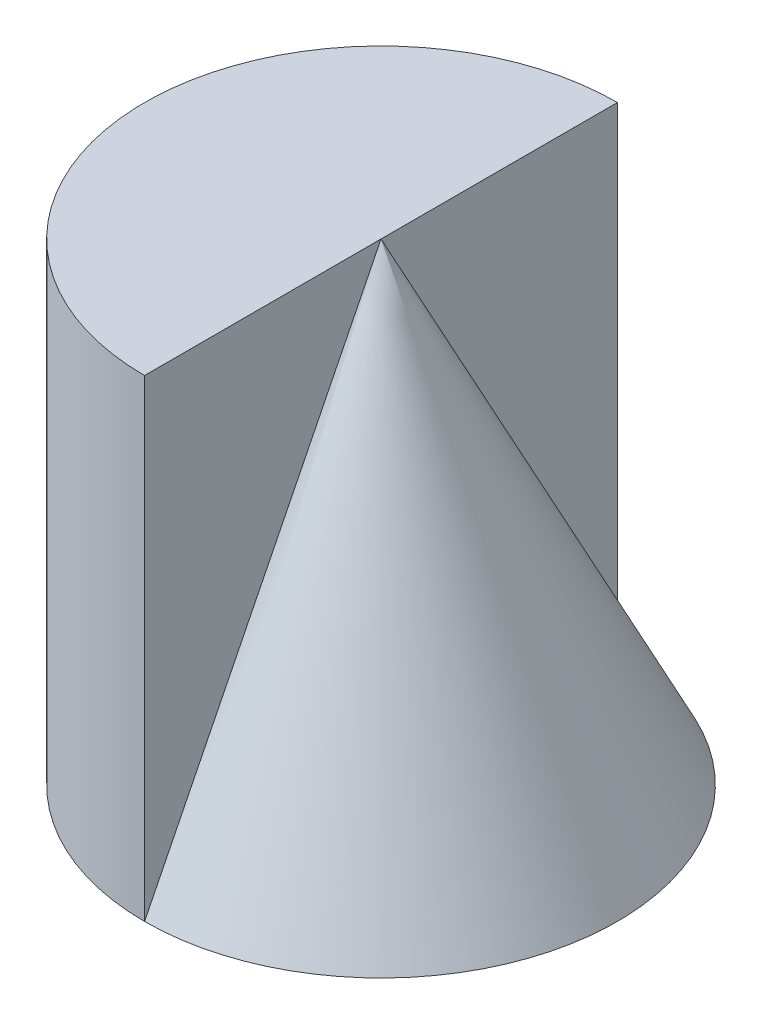
from build123d import *

# Parameters (mm, degrees)
SKETCH1_W           = 2
SKETCH1_H           = 4
BOSS_EXTRUDE1_DEPTH = 4
REVOLVE1_ANGLE      = 180
CUT_EXTRUDE1_DEPTH  = 4


with BuildPart() as part:
    # Sketch1 → Boss-Extrude1 (new body)
    with BuildSketch(Plane.XY):
        with Locations((1, 2)):
            Rectangle(SKETCH1_W, SKETCH1_H)
    extrude(amount=BOSS_EXTRUDE1_DEPTH)

    # Sketch2 → Revolve1 (revolve)
    with BuildSketch(Plane(origin=(2, 0, 0), x_dir=(0, 0, -1), z_dir=(1, 0, 0))):
        Polygon((-2, 0), (-2, 4), (0, 0), align=None)
    revolve(axis=Axis((2, 0, 2), (0, -1, 0)), revolution_arc=REVOLVE1_ANGLE)

    # Sketch3 → Cut-Extrude1 (cut)
    with BuildSketch(Plane(origin=(0, 4, 0), x_dir=(1, 0, 0), z_dir=(0, 1, 0))):
        with BuildLine():
            Line((0, -4), (2, -4))
            ThreePointArc((2, -4), (0.585786438, -3.414213562), (0, -2))
            Line((0, -2), (0, -4))
        make_face()
        with BuildLine():
            ThreePointArc((0, -2), (0.585786438, -0.585786438), (2, 0))
            Line((2, 0), (0, 0))
            Line((0, 0), (0, -2))
        make_face()
    extrude(amount=-CUT_EXTRUDE1_DEPTH, mode=Mode.SUBTRACT)


solid = part.part
